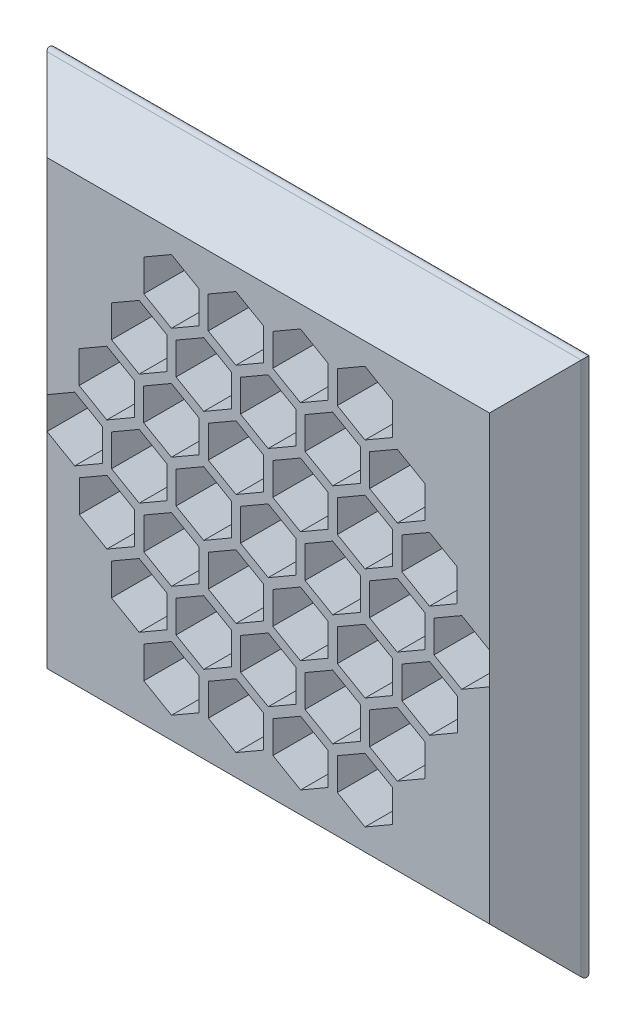
from build123d import *

# Parameters (mm, degrees)
SKETCH1_W           = 100
SKETCH1_H           = 100
BOSS_EXTRUDE1_DEPTH = 10
BOSS_EXTRUDE1_TAPER = 45
FILLET1_R           = 1
CUT_EXTRUDE1_DEPTH  = 11


with BuildPart() as part:
    # Sketch1 → Boss-Extrude1 (new body)
    with BuildSketch(Plane.XY):
        Rectangle(SKETCH1_W, SKETCH1_H)
    extrude(amount=BOSS_EXTRUDE1_DEPTH, taper=BOSS_EXTRUDE1_TAPER)

    # Fillet1
    fillet1_edges = [part.edges().sort_by_distance(p)[0] for p in [
        (0, -50, 0),
        (-50, 0, 0),
        (0, 50, 0),
        (50, 0, 0),
    ]]
    fillet(fillet1_edges, radius=FILLET1_R)

    # Sketch3 → Cut-Extrude1 (cut, through all)
    with BuildSketch(Plane(origin=(0, 0, 0), x_dir=(-1, 0, 0), z_dir=(0, 0, -1))):
        Polygon((-17.49, 24.520065932), (-12.49, 27.406817278), (-12.49, 33.18031997), (-17.49, 36.067071316), (-22.49, 33.18031997), (-22.49, 27.406817278), align=None)
        Polygon((-5.825, 24.528726187), (-0.825, 27.415477532), (-0.825, 33.188980224), (-5.825, 36.07573157), (-10.825, 33.188980224), (-10.825, 27.415477532), align=None)
        Polygon((5.84558039, 24.54705196), (10.84558039, 27.433803306), (10.84558039, 33.207305998), (5.84558039, 36.094057344), (0.84558039, 33.207305998), (0.84558039, 27.433803306), align=None)
        Polygon((12.49, 27.406817278), (17.49, 24.520065932), (22.49, 27.406817278), (22.49, 33.18031997), (17.49, 36.067071316), (12.49, 33.18031997), align=None)
        Polygon((24.18116078, 7.211104862), (29.18116078, 4.324353516), (34.18116078, 7.211104862), (34.18116078, 12.984607554), (29.18116078, 15.8713589), (24.18116078, 12.984607554), align=None)
        Polygon((18.33, 17.30896107), (23.33, 14.422209724), (28.33, 17.30896107), (28.33, 23.082463762), (23.33, 25.969215108), (18.33, 23.082463762), align=None)
        Polygon((6.66, 17.30896107), (11.66, 14.422209724), (16.66, 17.30896107), (16.66, 23.082463762), (11.66, 25.969215108), (6.66, 23.082463762), align=None)
        Polygon((0.007790195, 14.435702738), (5.007790195, 17.322454084), (5.007790195, 23.095956776), (0.007790195, 25.982708122), (-4.992209805, 23.095956776), (-4.992209805, 17.322454084), align=None)
        Polygon((-11.66, 14.422209724), (-6.66, 17.30896107), (-6.66, 23.082463762), (-11.66, 25.969215108), (-16.66, 23.082463762), (-16.66, 17.30896107), align=None)
        Polygon((-18.33558039, 17.335947098), (-18.33558039, 23.109449789), (-23.33558039, 25.996201135), (-28.33558039, 23.109449789), (-28.33558039, 17.335947098), (-23.33558039, 14.449195752), align=None)
        Polygon((-24.155, 7.219765116), (-24.155, 12.993267808), (-29.155, 15.880019154), (-34.155, 12.993267808), (-34.155, 7.219765116), (-29.155, 4.33301377), align=None)
        Polygon((-12.497790195, 7.224597876), (-12.497790195, 12.998100568), (-17.497790195, 15.884851914), (-22.497790195, 12.998100568), (-22.497790195, 7.224597876), (-17.497790195, 4.33784653), align=None)
        Polygon((-5.83, 4.324353516), (-0.83, 7.211104862), (-0.83, 12.984607554), (-5.83, 15.8713589), (-10.83, 12.984607554), (-10.83, 7.211104862), align=None)
        Polygon((0.83, 7.211104862), (5.83, 4.324353516), (10.83, 7.211104862), (10.83, 12.984607554), (5.83, 15.8713589), (0.83, 12.984607554), align=None)
        Polygon((12.50558039, 7.211104862), (17.50558039, 4.324353516), (22.50558039, 7.211104862), (22.50558039, 12.984607554), (17.50558039, 15.8713589), (12.50558039, 12.984607554), align=None)
        Polygon((18.32, 2.886751346), (18.32, -2.886751346), (23.32, -5.773502692), (28.32, -2.886751346), (28.32, 2.886751346), (23.32, 5.773502692), align=None)
        Polygon((29.98, 2.886751346), (29.98, -2.886751346), (34.98, -5.773502692), (39.98, -2.886751346), (39.98, 2.886751346), (34.98, 5.773502692), align=None)
        Polygon((24.155, -7.219765116), (24.155, -12.993267808), (29.155, -15.880019154), (34.155, -12.993267808), (34.155, -7.219765116), (29.155, -4.33301377), align=None)
        Polygon((12.497790195, -7.224597876), (12.497790195, -12.998100568), (17.497790195, -15.884851914), (22.497790195, -12.998100568), (22.497790195, -7.224597876), (17.497790195, -4.33784653), align=None)
        Polygon((6.66, 2.886751346), (6.66, -2.886751346), (11.66, -5.773502692), (16.66, -2.886751346), (16.66, 2.886751346), (11.66, 5.773502692), align=None)
        Polygon((5.83, -4.324353516), (0.83, -7.211104862), (0.83, -12.984607554), (5.83, -15.8713589), (10.83, -12.984607554), (10.83, -7.211104862), align=None)
        Polygon((-6.66, -2.886751346), (-6.66, 2.886751346), (-11.66, 5.773502692), (-16.66, 2.886751346), (-16.66, -2.886751346), (-11.66, -5.773502692), align=None)
        Polygon((-18.32, -2.886751346), (-18.32, 2.886751346), (-23.32, 5.773502692), (-28.32, 2.886751346), (-28.32, -2.886751346), (-23.32, -5.773502692), align=None)
        Polygon((-29.98, -2.886751346), (-29.98, 2.886751346), (-34.98, 5.773502692), (-39.98, 2.886751346), (-39.98, -2.886751346), (-34.98, -5.773502692), align=None)
        Polygon((-24.18116078, -7.211104862), (-29.18116078, -4.324353516), (-34.18116078, -7.211104862), (-34.18116078, -12.984607554), (-29.18116078, -15.8713589), (-24.18116078, -12.984607554), align=None)
        Polygon((-12.50558039, -7.211104862), (-17.50558039, -4.324353516), (-22.50558039, -7.211104862), (-22.50558039, -12.984607554), (-17.50558039, -15.8713589), (-12.50558039, -12.984607554), align=None)
        Polygon((-0.83, -7.211104862), (-5.83, -4.324353516), (-10.83, -7.211104862), (-10.83, -12.984607554), (-5.83, -15.8713589), (-0.83, -12.984607554), align=None)
        Polygon((11.66, -14.422209724), (6.66, -17.30896107), (6.66, -23.082463762), (11.66, -25.969215108), (16.66, -23.082463762), (16.66, -17.30896107), align=None)
        Polygon((18.33558039, -17.335947098), (18.33558039, -23.109449789), (23.33558039, -25.996201135), (28.33558039, -23.109449789), (28.33558039, -17.335947098), (23.33558039, -14.449195752), align=None)
        Polygon((17.49, -24.520065932), (12.49, -27.406817278), (12.49, -33.18031997), (17.49, -36.067071316), (22.49, -33.18031997), (22.49, -27.406817278), align=None)
        Polygon((-12.49, -27.406817278), (-17.49, -24.520065932), (-22.49, -27.406817278), (-22.49, -33.18031997), (-17.49, -36.067071316), (-12.49, -33.18031997), align=None)
        Polygon((-18.33, -17.30896107), (-23.33, -14.422209724), (-28.33, -17.30896107), (-28.33, -23.082463762), (-23.33, -25.969215108), (-18.33, -23.082463762), align=None)
        Polygon((-6.66, -17.30896107), (-11.66, -14.422209724), (-16.66, -17.30896107), (-16.66, -23.082463762), (-11.66, -25.969215108), (-6.66, -23.082463762), align=None)
        Polygon((-0.007790195, -14.435702738), (-5.007790195, -17.322454084), (-5.007790195, -23.095956776), (-0.007790195, -25.982708122), (4.992209805, -23.095956776), (4.992209805, -17.322454084), align=None)
        Polygon((5.825, -24.528726187), (0.825, -27.415477532), (0.825, -33.188980224), (5.825, -36.07573157), (10.825, -33.188980224), (10.825, -27.415477532), align=None)
        Polygon((-5.84558039, -24.54705196), (-10.84558039, -27.433803306), (-10.84558039, -33.207305998), (-5.84558039, -36.094057344), (-0.84558039, -33.207305998), (-0.84558039, -27.433803306), align=None)
        Polygon((0, -5.773502692), (5, -2.886751346), (5, 2.886751346), (0, 5.773502692), (-5, 2.886751346), (-5, -2.886751346), align=None)
    extrude(amount=-CUT_EXTRUDE1_DEPTH, mode=Mode.SUBTRACT)


solid = part.part
